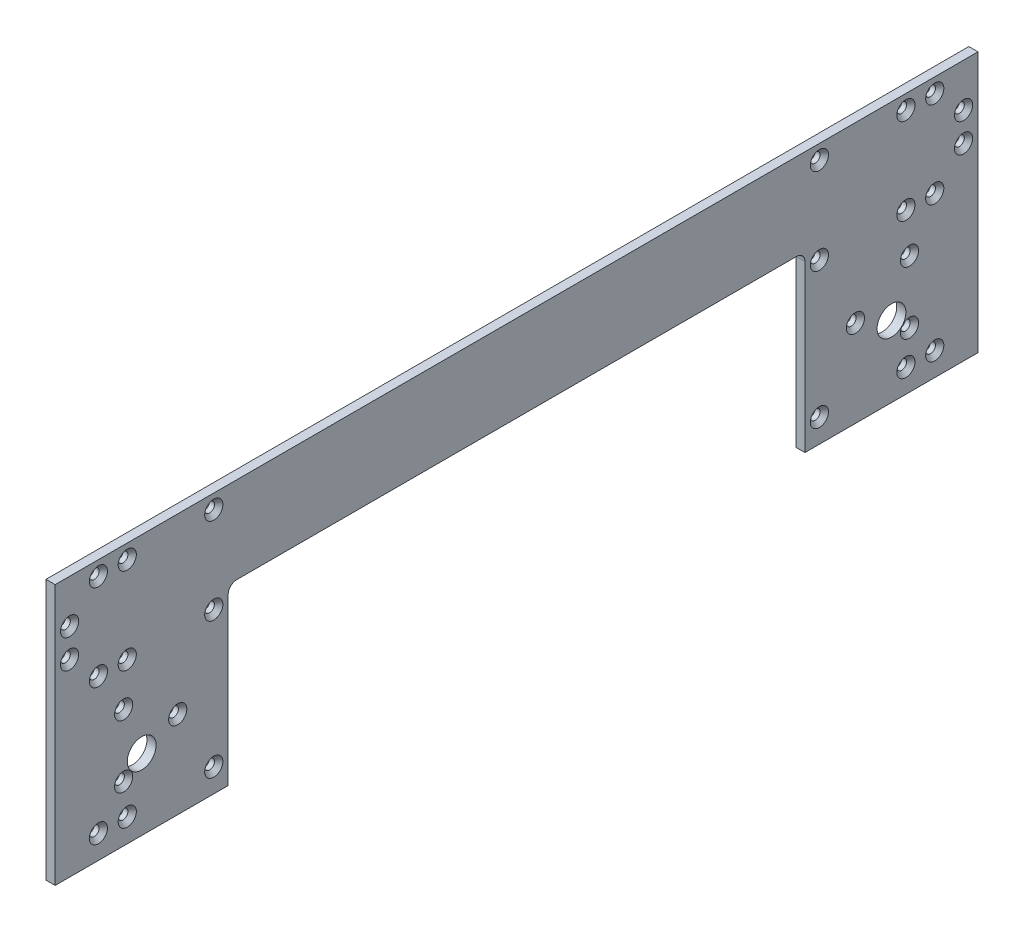
from build123d import *

# Parameters (mm, degrees)
BOSS_EXTRUDE1_DEPTH                             = 3.175
CSK_FOR_M3_FLAT_HEAD_MACHINE_SCREW1_D           = 3.4
CSK_FOR_M3_FLAT_HEAD_MACHINE_SCREW1_CSINK_D     = 6.3
CSK_FOR_M3_FLAT_HEAD_MACHINE_SCREW1_CSINK_ANGLE = 90
SKETCH4_R                                       = 5
CUT_EXTRUDE1_DEPTH                              = 4.175


with BuildPart() as part:
    # Sketch1 → Boss-Extrude1 (new body)
    with BuildSketch(Plane(origin=(0, 0, 0), x_dir=(0, 0, -1), z_dir=(1, 0, 0))):
        Polygon((160, 0), (160, 3.175), (160, 47.175), (160, 50.35), (160, 60.35), (160, 90.35), (-160, 90.35), (-160, 60.35), (-160, 50.35), (-160, 47.175), (-160, 3.175), (-160, 0), align=None)
    extrude(amount=BOSS_EXTRUDE1_DEPTH)

    # CSK for M3 Flat Head Machine Screw1 (through all)
    with Locations(Plane(origin=(3.175, 0, 0), x_dir=(0, 0, -1), z_dir=(1, 0, 0))):
        with Locations((-145, 8.175), (-135, 8.175), (-105, 8.175), (-145, 55.35), (-135, 55.35), (-105, 55.35), (-117.5, 30.175), (-136.25, 19.349682453), (-136.25, 41.000317547), (-145, 85.35), (-135, 85.35), (-105, 85.35), (-155, 65.35), (-155, 75.35)):
            csk_for_m3_flat_head_machine_screw1 = CounterSinkHole(CSK_FOR_M3_FLAT_HEAD_MACHINE_SCREW1_D / 2, CSK_FOR_M3_FLAT_HEAD_MACHINE_SCREW1_CSINK_D / 2, counter_sink_angle=CSK_FOR_M3_FLAT_HEAD_MACHINE_SCREW1_CSINK_ANGLE)

    # Mirror1: CSK for M3 Flat Head Machine Screw1 across plane
    add(csk_for_m3_flat_head_machine_screw1.mirror(Plane.XY), mode=Mode.SUBTRACT)

    # Sketch4 → Cut-Extrude1 (cut, through all)
    with BuildSketch(Plane(origin=(3.175, 0, 0), x_dir=(0, 0, -1), z_dir=(1, 0, 0))):
        with Locations((-130, 24.675)):
            Circle(SKETCH4_R)
        with Locations((130, 24.675)):
            Circle(SKETCH4_R)
        with BuildLine():
            Line((-100, 57.35), (-100, 0))
            Line((-100, 0), (100, 0))
            Line((100, 0), (100, 57.35))
            ThreePointArc((100, 57.35), (99.121320344, 59.471320344), (97, 60.35))
            Line((97, 60.35), (-97, 60.35))
            ThreePointArc((-97, 60.35), (-99.121320344, 59.471320344), (-100, 57.35))
        make_face()
    extrude(amount=-CUT_EXTRUDE1_DEPTH, mode=Mode.SUBTRACT)


solid = part.part
